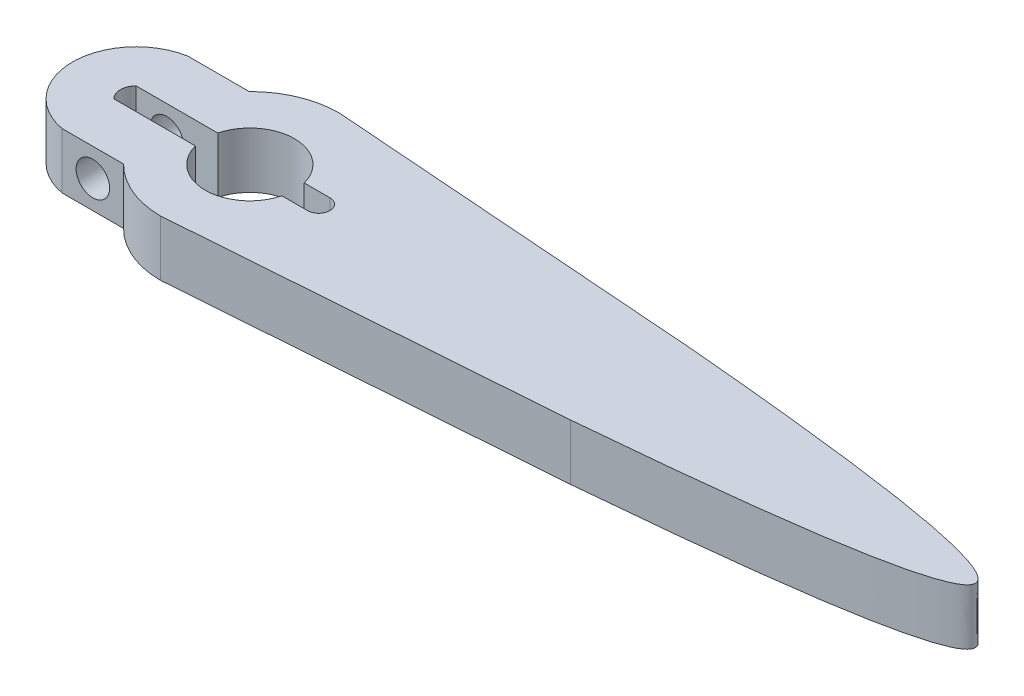
from build123d import *

# Parameters (mm, degrees)
SKETCH1_R               = 4
BOSS_EXTRUDE1_DEPTH     = 5
CUT_EXTRUDE1_DEPTH      = 6.0000001
BOSS_EXTRUDE3_DEPTH     = 5
SKETCH7_R               = 1.5
CUT_EXTRUDE2_DEPTH      = 3.373709786
CUT_EXTRUDE2_DEPTH_BACK = 14.626290414


with BuildPart() as part:
    # Sketch1 → Boss-Extrude1 (new body)
    with BuildSketch(Plane(origin=(0, 0, 0), x_dir=(1, 0, 0), z_dir=(0, 1, 0))):
        with BuildLine():
            Line((-2.5, 8), (31.690345961, 5.462833873))
            add(Edge.make_bspline(
                [(31.690345961, 5.462833873), (93.309654039, 0), (31.690345961, -5.462833873)],
                knots=[0, 0, 0, 1, 1, 1], degree=2))
            Line((31.690345961, -5.462833873), (-2.5, -8))
            ThreePointArc((-2.5, -8), (-10.5, 0), (-2.5, 8))
        make_face()
        with Locations((-2.5, 0)):
            Circle(SKETCH1_R, mode=Mode.SUBTRACT)
    extrude(amount=BOSS_EXTRUDE1_DEPTH)

    # Sketch5 → Cut-Extrude1 (cut, through all)
    with BuildSketch(Plane(origin=(0, 5, 0), x_dir=(1, 0, 0), z_dir=(0, 1, 0))):
        with BuildLine():
            Line((1.372805365, -1.000689064), (3.672323333, -1.000689064))
            ThreePointArc((3.672323333, -1.000689064), (4.673012397, 0), (3.672323333, 1.000689064))
            Line((3.672323333, 1.000689064), (1.372805365, 1.000689064))
            ThreePointArc((1.372805365, 1.000689064), (1.5, 0), (1.372805365, -1.000689064))
        make_face()
        with BuildLine():
            Line((-6.372983346, 1), (-10.437253933, 1))
            ThreePointArc((-10.437253933, 1), (-10.5, 0), (-10.437253933, -1))
            Line((-10.437253933, -1), (-6.372983346, -1))
            ThreePointArc((-6.372983346, -1), (-6.5, 0), (-6.372983346, 1))
        make_face()
    extrude(amount=-CUT_EXTRUDE1_DEPTH, mode=Mode.SUBTRACT)

    # Sketch6 → Boss-Extrude3 (add)
    with BuildSketch(Plane(origin=(0, 5, 0), x_dir=(1, 0, 0), z_dir=(0, 1, 0))):
        with BuildLine():
            Line((-13.687253933, 1), (-10.437253933, 1))
            ThreePointArc((-10.437253933, 1), (-9.694264672, 3.498936386), (-8.187253933, 5.626290314))
            Line((-8.187253933, 5.626290314), (-13.687253933, 5.626290314))
            ThreePointArc((-13.687253933, 5.626290314), (-18.394261839, 0), (-13.687253933, -5.626290314))
            Line((-13.687253933, -5.626290314), (-8.187253933, -5.626290314))
            ThreePointArc((-8.187253933, -5.626290314), (-9.694264672, -3.498936386), (-10.437253933, -1))
            Line((-10.437253933, -1), (-13.687253933, -1))
            ThreePointArc((-13.687253933, -1), (-14.098831021, 0), (-13.687253933, 1))
        make_face()
    extrude(amount=-BOSS_EXTRUDE3_DEPTH)

    # Sketch7 → Cut-Extrude2 (cut, two sides)
    with BuildSketch(Plane(origin=(0, 0, -5.626290314), x_dir=(-1, 0, 0), z_dir=(0, 0, -1))) as cut_extrude2_sk:
        with Locations((10.937253933, 2.5)):
            Circle(SKETCH7_R)
    extrude(amount=CUT_EXTRUDE2_DEPTH, mode=Mode.SUBTRACT)
    extrude(cut_extrude2_sk.sketch, amount=-CUT_EXTRUDE2_DEPTH_BACK, mode=Mode.SUBTRACT)


solid = part.part
